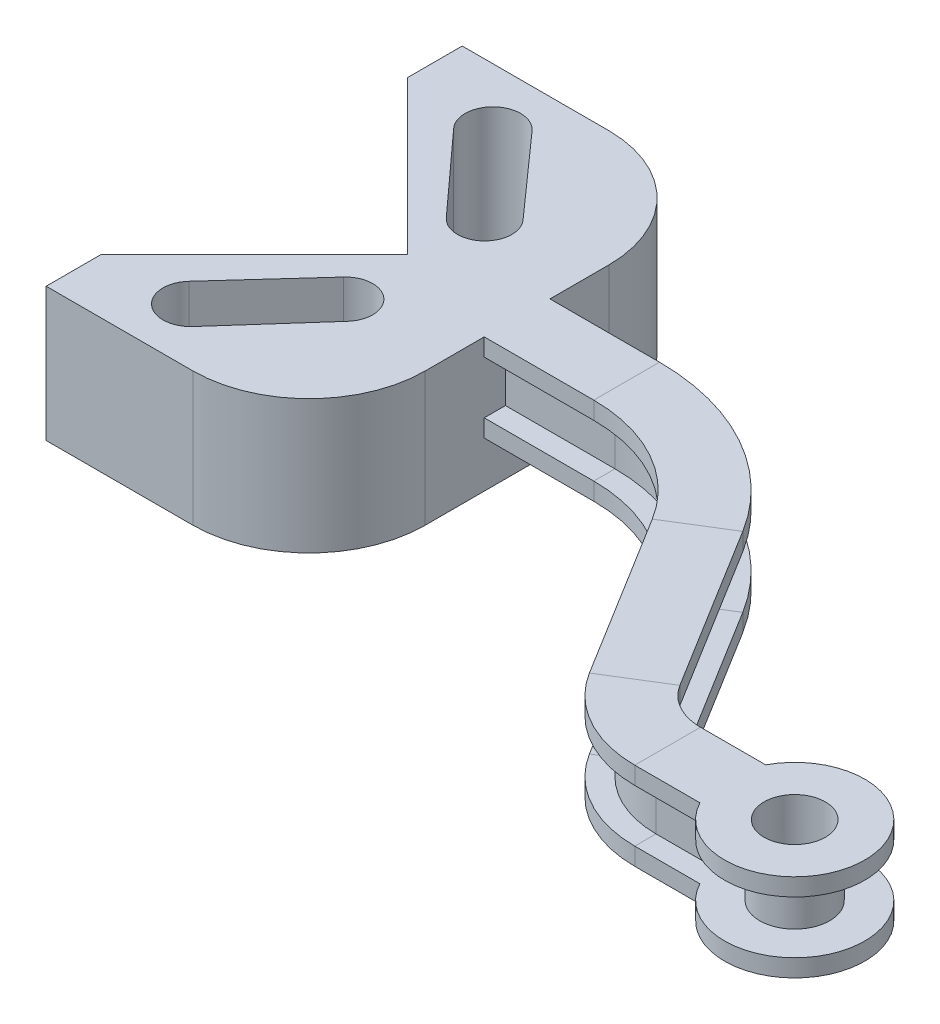
from build123d import *

# Parameters (mm, degrees)
BOSS_EXTRUDE1_DEPTH = 152.5
CUT_EXTRUDE1_DEPTH  = 153.5
CUT_EXTRUDE2_REACH  = 154.5
SKETCH7_R           = 35


with BuildPart() as part:
    # Sketch1 → Boss-Extrude1 (new body)
    with BuildSketch(Plane(origin=(0, 0, 0), x_dir=(1, 0, 0), z_dir=(0, 1, 0))):
        with BuildLine():
            Line((-300, -132.5), (-132.5, -132.5))
            ThreePointArc((-132.5, -132.5), (-38.808351493, -93.691648507), (0, 0))
            Line((0, 0), (0, 209.763098819))
            ThreePointArc((0, 209.763098819), (-38.808351493, 303.454747326), (-132.5, 342.263098819))
            Line((-132.5, 342.263098819), (-300, 342.263098819))
            Line((-300, 342.263098819), (-300, 279.881549409))
            Line((-300, 279.881549409), (-125, 104.881549409))
            Line((-125, 104.881549409), (-300, -70.118450591))
            Line((-300, -70.118450591), (-300, -132.5))
        make_face()
    extrude(amount=BOSS_EXTRUDE1_DEPTH)

    # Sketch2 → Cut-Extrude1 (cut, through all)
    with BuildSketch(Plane(origin=(0, 152.5, 0), x_dir=(1, 0, 0), z_dir=(0, 1, 0))):
        with BuildLine():
            Line((-223.447835998, -46.182307711), (-139.361825834, 46.305891731))
            ThreePointArc((-139.361825834, 46.305891731), (-95.697655057, 48.504400086), (-93.258215037, 4.853026901))
            Line((-93.258215037, 4.853026901), (-176.318308109, -88.557599262))
            ThreePointArc((-176.318308109, -88.557599262), (-221.187968417, -91.065122785), (-223.447835998, -46.182307711))
        make_face()
        with BuildLine():
            Line((-93.258215037, 204.910071918), (-176.318308109, 298.320698081))
            ThreePointArc((-176.318308109, 298.320698081), (-221.187968417, 300.828221603), (-223.447835998, 255.94540653))
            Line((-223.447835998, 255.94540653), (-139.361825834, 163.457207088))
            ThreePointArc((-139.361825834, 163.457207088), (-95.697655057, 161.258698732), (-93.258215037, 204.910071918))
        make_face()
    extrude(amount=-CUT_EXTRUDE1_DEPTH, mode=Mode.SUBTRACT)

    # Sweep2: sweep along a path in Sketch4
    with BuildLine(Plane(origin=(0, 0, 0), x_dir=(1, 0, 0), z_dir=(0, 1, 0))) as sweep2_path:
        Line((0, 104.881549409), (125, 104.881549409))
        ThreePointArc((125, 104.881549409), (229.686421658, 77.6733307), (307.876740467, 2.935066808))
        Line((307.876740467, 2.935066808), (424.108620349, -185.083031348))
        ThreePointArc((424.108620349, -185.083031348), (460.476210492, -219.845014554), (509.167569403, -232.5))
        Line((509.167569403, -232.5), (654.167569403, -232.5))
    # Sketch3 → Sweep2 (sweep)
    with BuildSketch(Plane(origin=(0, 0, 0), x_dir=(0, 0, -1), z_dir=(1, 0, 0))):
        Polygon((67.381549409, 152.5), (142.381549409, 152.5), (142.381549409, 132.5), (118.166896534, 132.5), (118.166896534, 72.5), (142.381549409, 72.5), (142.381549409, 52.5), (67.381549409, 52.5), (67.381549409, 72.5), (91.596202285, 72.5), (91.596202285, 132.5), (67.381549409, 132.5), align=None)
    sweep(path=sweep2_path.line)

    # Sketch6 → Revolve2 (revolve)
    with BuildSketch(Plane.XY.offset(232.5)):
        Polygon((654.167569403, 152.5), (574.167569403, 152.5), (574.167569403, 132.5), (614.167569403, 132.5), (614.167569403, 72.5), (574.167569403, 72.5), (574.167569403, 52.5), (654.167569403, 52.5), align=None)
    revolve(axis=Axis((654.167569403, 152.5, 232.5), (0, 1, 0)))

    # Sketch7 → Cut-Extrude2 (cut, up to next)
    with BuildSketch(Plane(origin=(0, 152.5, 0), x_dir=(1, 0, 0), z_dir=(0, 1, 0)), mode=Mode.PRIVATE) as cut_extrude2_sk1:
        with Locations((654.167569403, -232.5)):
            Circle(SKETCH7_R)
    cut_extrude2_tool1 = extrude(cut_extrude2_sk1.sketch, amount=-CUT_EXTRUDE2_REACH, mode=Mode.PRIVATE) & part.part
    add(cut_extrude2_tool1.solids().sort_by_distance((654.167569, 152.5, 232.5))[0], mode=Mode.SUBTRACT)


solid = part.part
